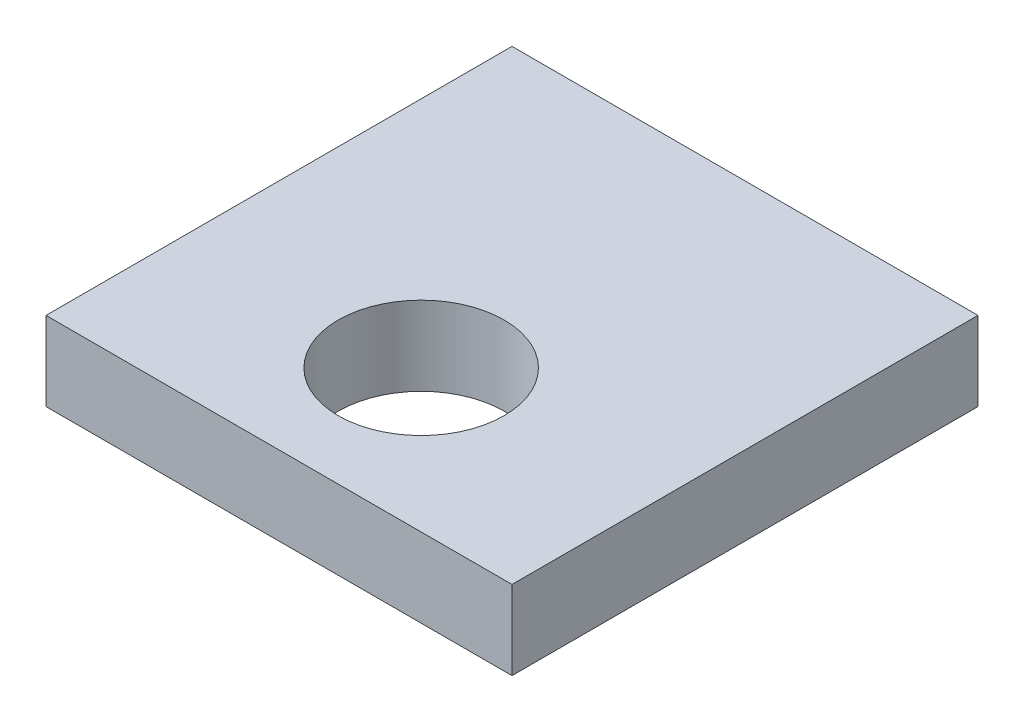
from build123d import *

# Parameters (mm, degrees)
ESQUISSE1_W        = 59
ESQUISSE1_H        = 59
ESQUISSE1_R        = 10.5
BOSS_EXTRU_2_DEPTH = 10


with BuildPart() as part:
    # Esquisse1 → Boss.-Extru.2 (new body)
    with BuildSketch(Plane(origin=(0, 0, 0), x_dir=(1, 0, 0), z_dir=(0, 1, 0))):
        with Locations((-11.773725289, -7.265444764)):
            Rectangle(ESQUISSE1_W, ESQUISSE1_H)
        with Locations((-11.773725289, -18.765444764)):
            Circle(ESQUISSE1_R, mode=Mode.SUBTRACT)
    extrude(amount=BOSS_EXTRU_2_DEPTH)


solid = part.part
